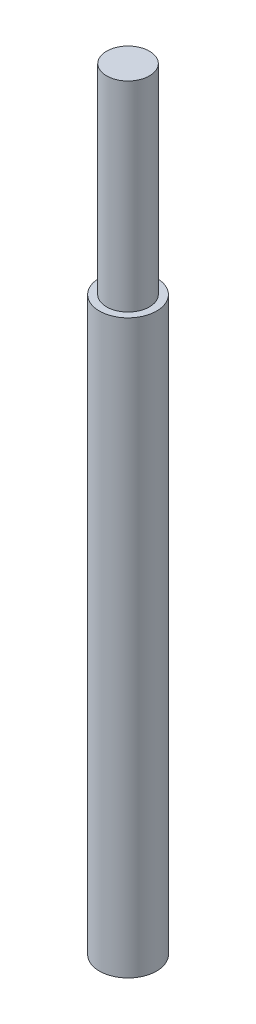
from build123d import *

# Parameters (mm, degrees)
CROQUIS1_R              = 7.5
SALIENTE_EXTRUIR1_DEPTH = 70
CROQUIS2_R              = 10
SALIENTE_EXTRUIR2_DEPTH = 200


with BuildPart() as part:
    # Croquis1 → Saliente-Extruir1 (new body)
    with BuildSketch(Plane(origin=(0, 0, 0), x_dir=(1, 0, 0), z_dir=(0, 1, 0))):
        Circle(CROQUIS1_R)
    extrude(amount=SALIENTE_EXTRUIR1_DEPTH)

    # Croquis2 → Saliente-Extruir2 (add)
    with BuildSketch(Plane.XZ):
        Circle(CROQUIS2_R)
    extrude(amount=SALIENTE_EXTRUIR2_DEPTH)


solid = part.part
